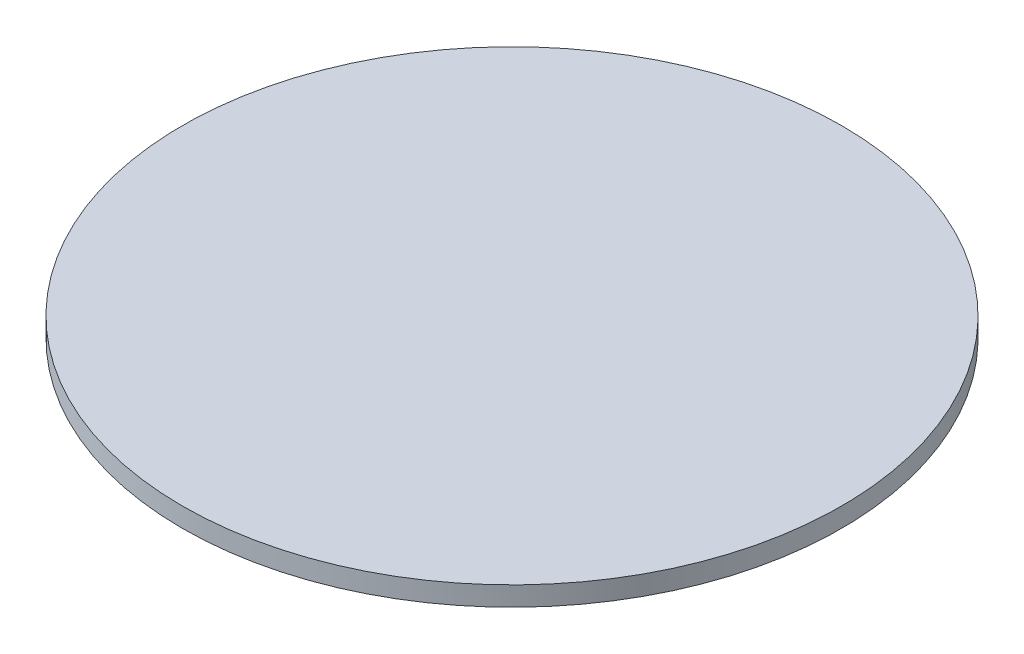
from build123d import *

# Parameters (mm, degrees)
SKETCH1_R           = 51
BOSS_EXTRUDE1_DEPTH = 3


with BuildPart() as part:
    # Sketch1 → Boss-Extrude1 (new body)
    with BuildSketch(Plane(origin=(0, 0, 0), x_dir=(1, 0, 0), z_dir=(0, 1, 0))):
        with Locations((8.815546452, 5.829461803)):
            Circle(SKETCH1_R)
    extrude(amount=BOSS_EXTRUDE1_DEPTH)


solid = part.part
